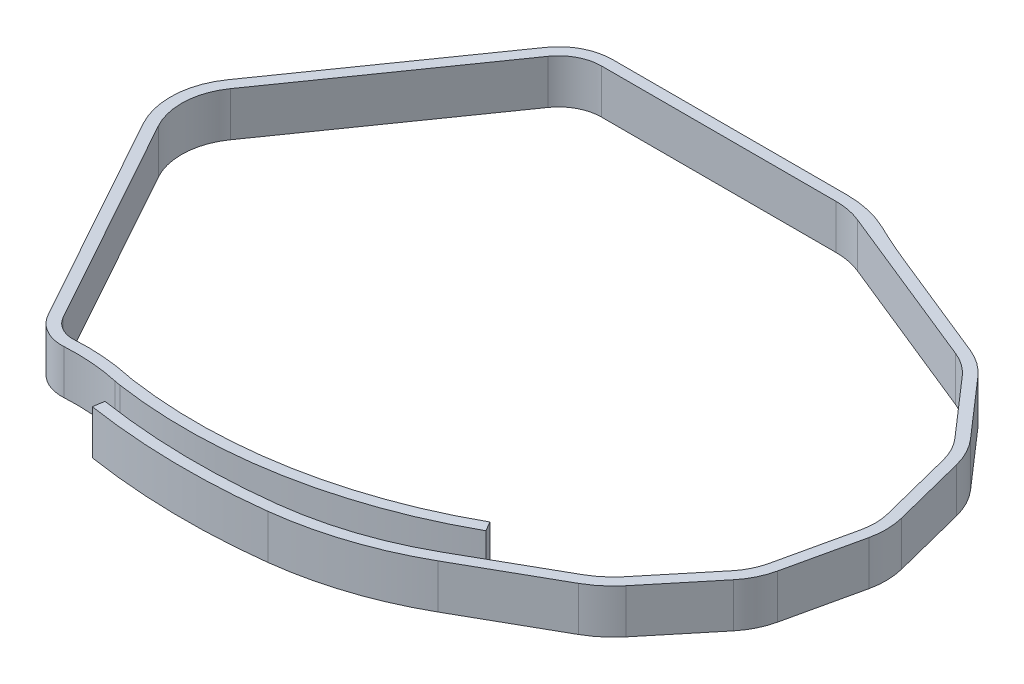
from build123d import *

# Parameters (mm, degrees)
BOSS_EXTRUDE1_DEPTH = 4


with BuildPart() as part:
    # Sketch1 → Boss-Extrude1 (new body)
    with BuildSketch(Plane(origin=(0, 0, 0), x_dir=(1, 0, 0), z_dir=(0, 1, 0))):
        with BuildLine():
            ThreePointArc((30.815272538, -36.001699489), (25.402435992, -38.396198014), (19.625399795, -39.683938449))
            ThreePointArc((19.625399795, -39.683938449), (11.702107234, -40.100543502), (3.79576222, -39.435838094))
            Line((3.79576222, -39.435838094), (3.644269307, -40.424296438))
            ThreePointArc((3.644269307, -40.424296438), (11.686436005, -41.100420701), (19.745841387, -40.676658864))
            ThreePointArc((19.745841387, -40.676658864), (25.715015737, -39.346089535), (31.307877538, -36.871952506))
            Line((31.307877538, -36.871952506), (39.401230599, -32.290726007))
            ThreePointArc((39.401230599, -32.290726007), (40.654759367, -31.420634412), (41.728618671, -30.336558791))
            Line((41.728618671, -30.336558791), (46.115294675, -25.01048391))
            ThreePointArc((46.115294675, -25.01048391), (46.926204525, -23.750298002), (47.422252359, -22.336232991))
            Line((47.422252359, -22.336232991), (48.929279873, -15.602818696))
            ThreePointArc((48.929279873, -15.602818696), (49.083336252, -14.112211456), (48.886975652, -12.626585049))
            Line((48.886975652, -12.626585049), (47.189177971, -5.938724177))
            ThreePointArc((47.189177971, -5.938724177), (46.653139583, -4.539329252), (45.806739977, -3.302700361))
            Line((45.806739977, -3.302700361), (41.270456965, 1.896543473))
            ThreePointArc((41.270456965, 1.896543473), (40.159986728, 2.902773645), (38.846178779, 3.62357319))
            Line((38.846178779, 3.62357319), (28.678343339, 7.739009747))
            ThreePointArc((28.678343339, 7.739009747), (26.957465579, 8.469564765), (25.262216259, 9.257765654))
            ThreePointArc((25.262216259, 9.257765654), (23.267121819, 9.961406596), (21.165078625, 10.2))
            Line((21.165078625, 10.2), (0, 10.2))
            ThreePointArc((0, 10.2), (-2.249376643, 9.649581037), (-3.9904429, 8.122706909))
            Line((-3.9904429, 8.122706909), (-15.810441253, -8.758000179))
            ThreePointArc((-15.810441253, -8.758000179), (-17.037346005, -12.320539523), (-16.190374911, -15.991999971))
            Line((-16.190374911, -15.991999971), (-5.517086169, -35.257340666))
            ThreePointArc((-5.517086169, -35.257340666), (-4.183080077, -36.586813335), (-2.345658451, -37.000276272))
            ThreePointArc((-2.345658451, -37.000276272), (0.184189718, -37.023630883), (2.686718995, -37.395147249))
            ThreePointArc((2.686718995, -37.395147249), (2.95899063, -37.449951511), (3.233042455, -37.495017541))
            ThreePointArc((3.233042455, -37.495017541), (17.592116724, -37.228639758), (31.102694288, -32.358499632))
            Line((31.102694288, -32.358499632), (30.614795368, -31.485599499))
            ThreePointArc((30.614795368, -31.485599499), (17.410864376, -36.245203137), (3.377694822, -36.505535003))
            ThreePointArc((3.377694822, -36.505535003), (3.138815013, -36.466252781), (2.901486924, -36.418482139))
            ThreePointArc((2.901486924, -36.418482139), (0.262415361, -36.026695204), (-2.405465658, -36.002066325))
            ThreePointArc((-2.405465658, -36.002066325), (-3.701447688, -35.710439989), (-4.642357438, -34.772727782))
            Line((-4.642357438, -34.772727782), (-15.31564618, -15.507387087))
            ThreePointArc((-15.31564618, -15.507387087), (-16.038722362, -12.372987788), (-14.991289209, -9.331576615))
            Line((-14.991289209, -9.331576615), (-3.171290856, 7.549130473))
            ThreePointArc((-3.171290856, 7.549130473), (-1.78762803, 8.762570204), (0, 9.2))
            Line((0, 9.2), (21.174669732, 9.2))
            ThreePointArc((21.174669732, 9.2), (22.380727426, 9.083680421), (23.542324402, 8.739009747))
            Line((23.542324402, 8.739009747), (32.075036736, 5.285390097))
            Line((32.075036736, 5.285390097), (38.470995099, 2.696622703))
            ThreePointArc((38.470995099, 2.696622703), (39.579771769, 2.088310262), (40.516943366, 1.239111152))
            Line((40.516943366, 1.239111152), (45.053226377, -3.960132681))
            ThreePointArc((45.053226377, -3.960132681), (45.767537886, -5.003774765), (46.219922772, -6.184781812))
            Line((46.219922772, -6.184781812), (47.917720454, -12.872642684))
            ThreePointArc((47.917720454, -12.872642684), (48.083437256, -14.126424033), (47.953422729, -15.384408911))
            Line((47.953422729, -15.384408911), (46.446395215, -22.117823206))
            ThreePointArc((46.446395215, -22.117823206), (46.027760006, -23.311210944), (45.343399765, -24.374733765))
            Line((45.343399765, -24.374733765), (40.956723761, -29.700808646))
            ThreePointArc((40.956723761, -29.700808646), (40.011729115, -30.654793636), (38.908625599, -31.42047299))
            Line((38.908625599, -31.42047299), (30.815272538, -36.001699489))
        make_face()
    extrude(amount=BOSS_EXTRUDE1_DEPTH)


solid = part.part
